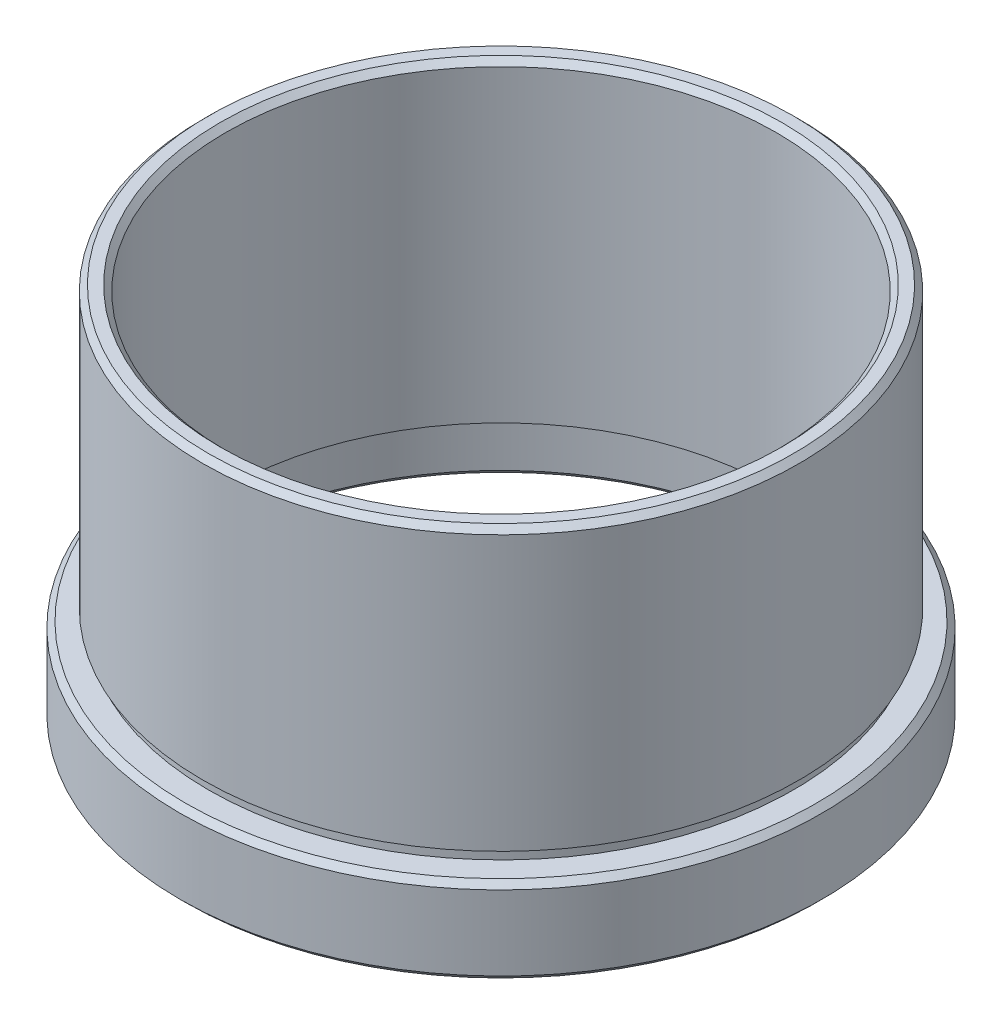
from build123d import *


with BuildPart() as part:
    # 草图1 → 旋转1 (revolve)
    with BuildSketch(Plane.XY, mode=Mode.PRIVATE) as revolve_1_sk:
        Polygon((24.5, 27.042854175), (25.5, 27.042854175), (26, 26.542854175), (26, 2.642854175), (25.5, 2.642854175), (25.5, 1.642854175), (27.5, 1.642854175), (28, 1.142854175), (28, -5.357145825), (27.5, -5.857145825), (26.5, -5.857145825), (26, -5.357145825), (26, -1.357145825), (26.1, -1.357145825), (26.1, -0.357145825), (24, -0.357145825), (24, 26.542854175), align=None)
    revolve(revolve_1_sk.sketch.rotate(Axis((0, 44.598597745, 0), (0, -1, 0)), 90), axis=Axis((0, 44.598597745, 0), (0, -1, 0)))  # turned: the seam where the file's is


solid = part.part
